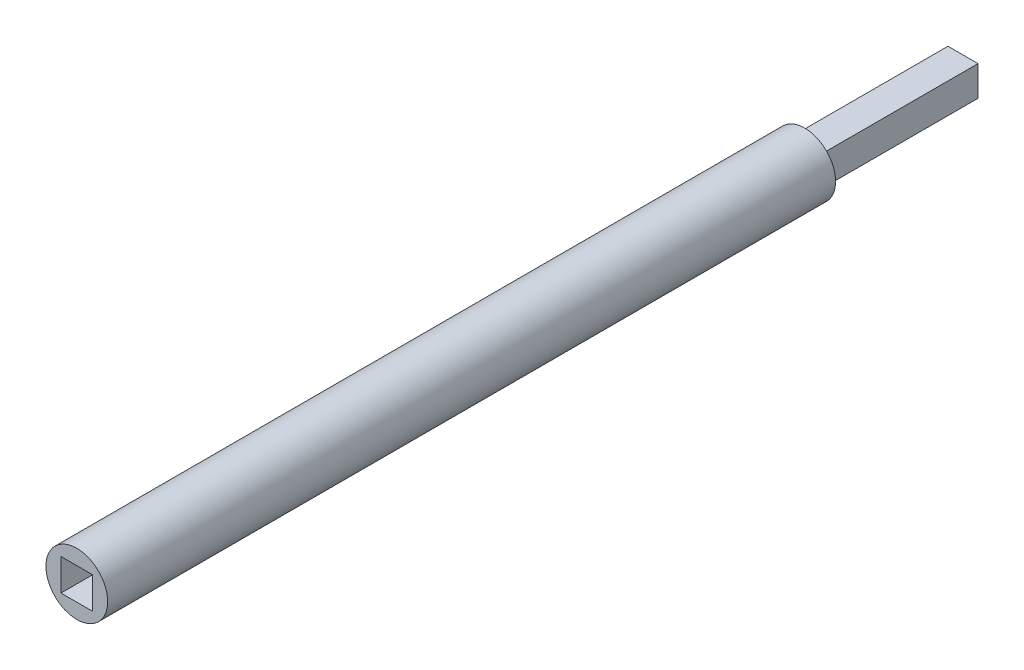
from build123d import *

# Parameters (mm, degrees)
SKETCH1_R           = 0.975
BOSS_EXTRUDE1_DEPTH = 23
SKETCH2_W           = 0.95
SKETCH2_H           = 0.95
BOSS_EXTRUDE2_DEPTH = 5
SKETCH3_W           = 1
SKETCH3_H           = 1
CUT_EXTRUDE1_DEPTH  = 5


with BuildPart() as part:
    # Sketch1 → Boss-Extrude1 (new body)
    with BuildSketch(Plane.XY):
        Circle(SKETCH1_R)
    extrude(amount=BOSS_EXTRUDE1_DEPTH)

    # Sketch2 → Boss-Extrude2 (add)
    with BuildSketch(Plane(origin=(0, 0, 0), x_dir=(-1, 0, 0), z_dir=(0, 0, -1))):
        Rectangle(SKETCH2_W, SKETCH2_H)
    extrude(amount=BOSS_EXTRUDE2_DEPTH)

    # Sketch3 → Cut-Extrude1 (cut)
    with BuildSketch(Plane.XY.offset(23)):
        Rectangle(SKETCH3_W, SKETCH3_H)
    extrude(amount=-CUT_EXTRUDE1_DEPTH, mode=Mode.SUBTRACT)


solid = part.part
